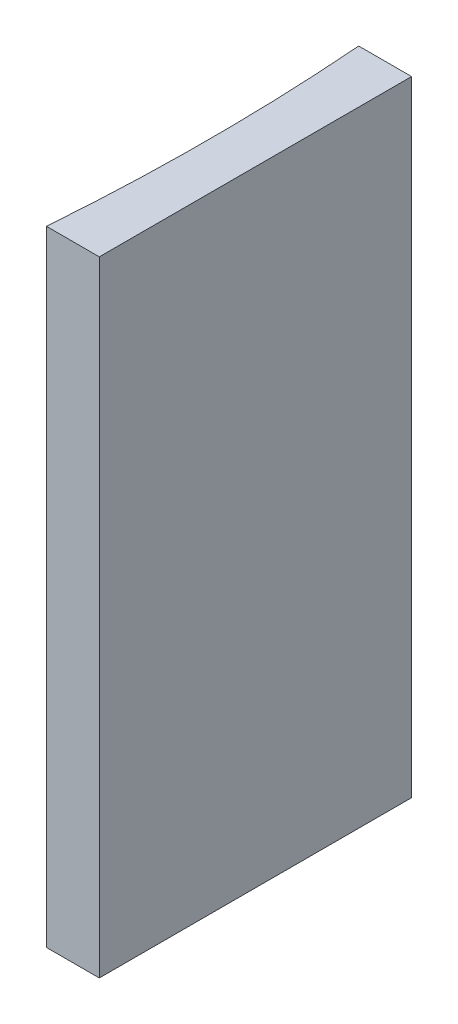
from build123d import *

# Parameters (mm, degrees)
EXTRUDE_1_DEPTH = 40


with BuildPart() as part:
    # 草图1 → 凸台-拉伸1 (new body)
    with BuildSketch(Plane(origin=(0, 0, 0), x_dir=(1, 0, 0), z_dir=(0, 1, 0))):
        with BuildLine():
            Line((0, 0), (0, -20))
            Line((0, -20), (-3.387427854, -20))
            ThreePointArc((-3.387427854, -20), (-3, -10), (-3.387427854, 0))
            Line((-3.387427854, 0), (0, 0))
        make_face()
    extrude(amount=EXTRUDE_1_DEPTH)


solid = part.part
